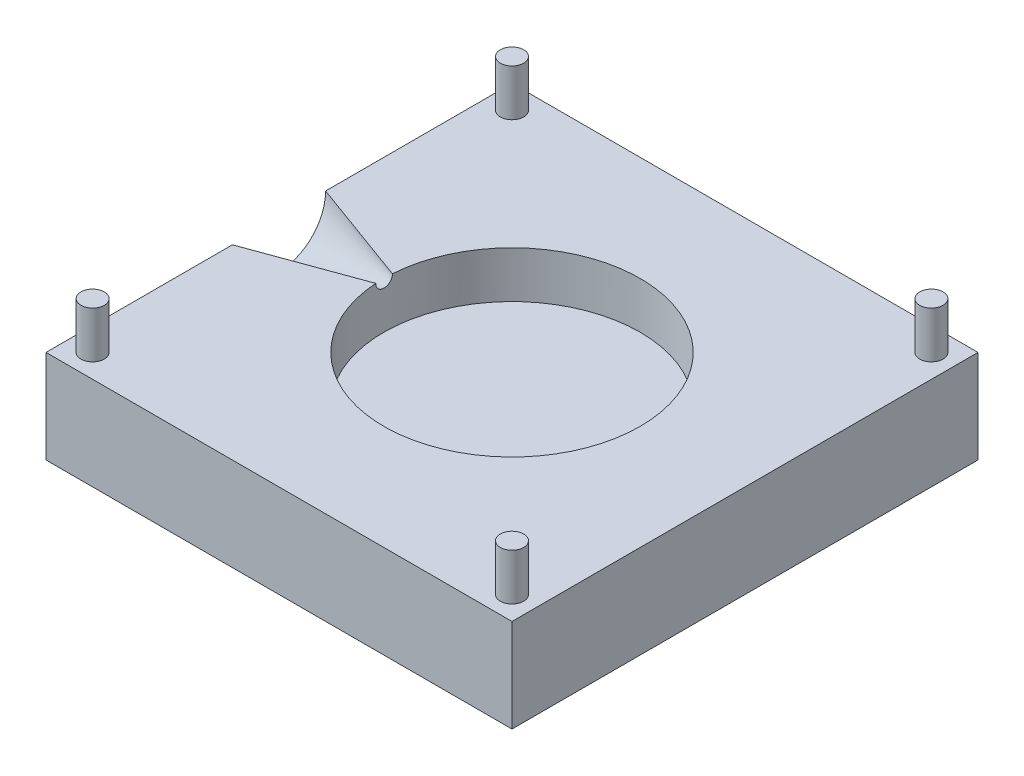
from build123d import *

# Parameters (mm, degrees)
SKETCH1_W           = 80
SKETCH1_H           = 80
BOSS_EXTRUDE1_DEPTH = 15
BOSS_EXTRUDE1_DRAFT = -5
SKETCH2_W           = 13.5
SKETCH2_H           = 72
SKETCH2_W_2         = 72
SKETCH2_H_2         = 13.5
CUT_EXTRUDE1_DEPTH  = 10
CUT_EXTRUDE1_TAPER  = 5
SKETCH3_R           = 27.5
BOSS_EXTRUDE2_DEPTH = 10
SKETCH4_W           = 100
SKETCH4_H           = 100
BOSS_EXTRUDE3_DEPTH = 20
SKETCH5_R           = 2.5
BOSS_EXTRUDE4_DEPTH = 10
CIRPATTERN1_COUNT   = 4
SKETCH6_R           = 10
CUT_EXTRUDE2_DEPTH  = 25
CUT_EXTRUDE2_DRAFT  = -20


with BuildPart() as part:
    # Sketch1 → Boss-Extrude1 (with draft: the straight prism first)
    with BuildSketch(Plane(origin=(0, 0, 0), x_dir=(1, 0, 0), z_dir=(0, 1, 0))):
        Rectangle(SKETCH1_W, SKETCH1_H)
    extrude(amount=BOSS_EXTRUDE1_DEPTH)
    # Boss-Extrude1: the draft: its side faces are tilted about the plane it starts from
    boss_extrude1_sides = [part.faces().sort_by_distance(p)[0] for p in [
        (0, 7.5, 40),
        (40, 7.5, 0),
        (0, 7.5, -40),
        (-40, 7.5, 0),
    ]]
    draft(boss_extrude1_sides, Plane(origin=(0, 0, 0), x_dir=(1, 0, 0), z_dir=(0, 1, 0)), BOSS_EXTRUDE1_DRAFT)

    # Sketch2 → Cut-Extrude1 (cut)
    with BuildSketch(Plane(origin=(0, 15, 0), x_dir=(1, 0, 0), z_dir=(0, 1, 0))):
        Rectangle(SKETCH2_W, SKETCH2_H)
        Rectangle(SKETCH2_W_2, SKETCH2_H_2)
    extrude(amount=-CUT_EXTRUDE1_DEPTH, taper=CUT_EXTRUDE1_TAPER, mode=Mode.SUBTRACT)

    # Sketch3 → Boss-Extrude2 (add)
    with BuildSketch(Plane.XZ):
        with Locations(Location((0, 0, 0), (0, 0, 270))):  # turned: the seam where the file's is
            Circle(SKETCH3_R)
    extrude(amount=BOSS_EXTRUDE2_DEPTH)


with BuildPart() as body_2:
    # Sketch4 → Boss-Extrude3 (new body)
    with BuildSketch(Plane.XZ):
        Rectangle(SKETCH4_W, SKETCH4_H)
    extrude(amount=BOSS_EXTRUDE3_DEPTH)

    # Combine1: cut part
    add(part.part, mode=Mode.SUBTRACT)

    # Sketch5 → Boss-Extrude4 (add)
    with BuildSketch(Plane(origin=(0, 0, 0), x_dir=(1, 0, 0), z_dir=(0, 1, 0))):
        with Locations(Location((-45, 45, 0), (0, 0, 270))):  # turned: the seam where the file's is
            Circle(SKETCH5_R)
    boss_extrude4 = extrude(amount=BOSS_EXTRUDE4_DEPTH)

    # CirPattern1: Boss-Extrude4 ×4 about axis
    cirpattern1_axis = Axis((0, 0, 0), (0, 1, 0))
    for i in range(1, CIRPATTERN1_COUNT):
        add(boss_extrude4.rotate(cirpattern1_axis, i * 360 / CIRPATTERN1_COUNT))


with BuildPart() as cut_extrude2_tool:
    # Sketch6 → Cut-Extrude2 (with draft: the straight prism first)
    with BuildSketch(Plane.ZY.offset(50)):
        Circle(SKETCH6_R)
    extrude(amount=-CUT_EXTRUDE2_DEPTH)
    # Cut-Extrude2: the draft: its side faces are tilted about the plane it starts from
    cut_extrude2_sides = [cut_extrude2_tool.faces().sort_by_distance(p)[0] for p in [
        (-37.5, 0, -10),
    ]]
    draft(cut_extrude2_sides, Plane.ZY.offset(50), CUT_EXTRUDE2_DRAFT)


with BuildPart() as body_2_1:
    add(body_2.part)

    # Cut-Extrude2: cut by cut_extrude2_tool
    add(cut_extrude2_tool.part, mode=Mode.SUBTRACT)


solid = body_2_1.part
